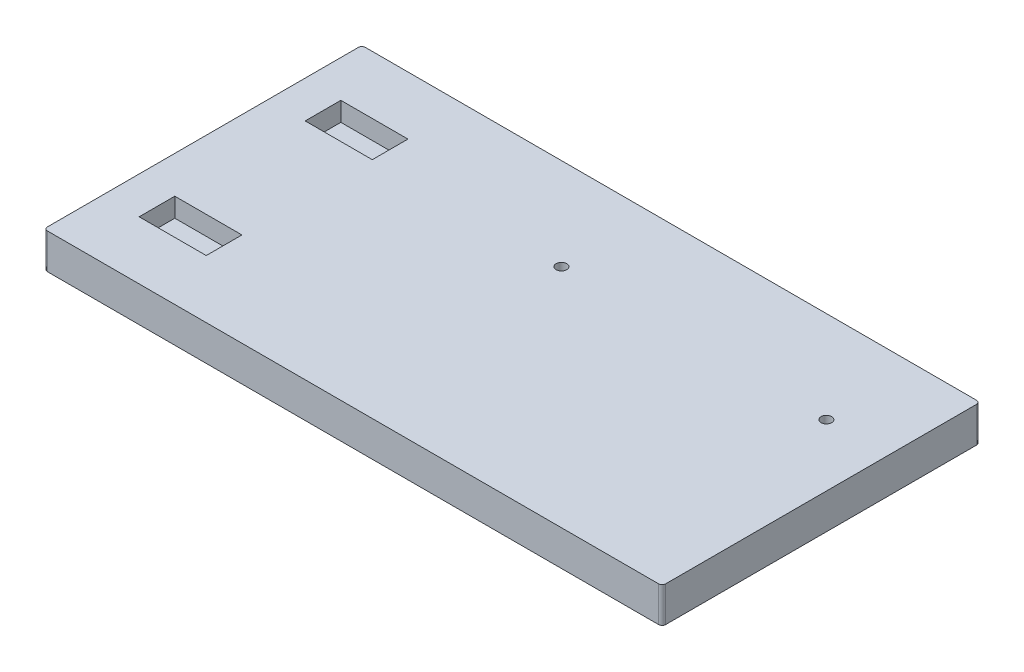
from build123d import *

# Parameters (mm, degrees)
SKETCH1_W           = 175
SKETCH1_H           = 90
BOSS_EXTRUDE1_DEPTH = 10
SKETCH2_W           = 19
SKETCH2_H           = 10.1
CUT_EXTRUDE1_DEPTH  = 5.4
SKETCH2_8_R         = 1.5
CUT_EXTRUDE3_DEPTH  = 99.900202224
FILLET1_R           = 1


with BuildPart() as part:
    # Sketch1 → Boss-Extrude1 (new body)
    with BuildSketch(Plane(origin=(0, 0, 0), x_dir=(1, 0, 0), z_dir=(0, 1, 0))):
        Rectangle(SKETCH1_W, SKETCH1_H)
    extrude(amount=BOSS_EXTRUDE1_DEPTH)

    # Sketch2 → Cut-Extrude1 (cut)
    with BuildSketch(Plane(origin=(0, 10, 0), x_dir=(1, 0, 0), z_dir=(0, 1, 0))):
        with Locations((-67.5, -23.5)):
            Rectangle(SKETCH2_W, SKETCH2_H)
    cut_extrude1 = extrude(amount=-CUT_EXTRUDE1_DEPTH, mode=Mode.SUBTRACT)

    # Mirror1: Cut-Extrude1 across plane
    add(cut_extrude1.mirror(Plane.XY), mode=Mode.SUBTRACT)

    # Sketch2_8 → Cut-Extrude3 (cut, through all)
    with BuildSketch(Plane(origin=(0, 10, 0), x_dir=(1, 0, 0), z_dir=(0, 1, 0))):
        with Locations((-5, 19)):
            Circle(SKETCH2_8_R)
        with Locations((70, 19)):
            Circle(SKETCH2_8_R)
    extrude(amount=-CUT_EXTRUDE3_DEPTH, mode=Mode.SUBTRACT)

    # Fillet1
    fillet1_edges = [part.edges().sort_by_distance(p)[0] for p in [
        (-87.5, 5, -45),
        (87.5, 5, -45),
        (87.5, 5, 45),
        (-87.5, 5, 45),
    ]]
    fillet(fillet1_edges, radius=FILLET1_R)


solid = part.part
